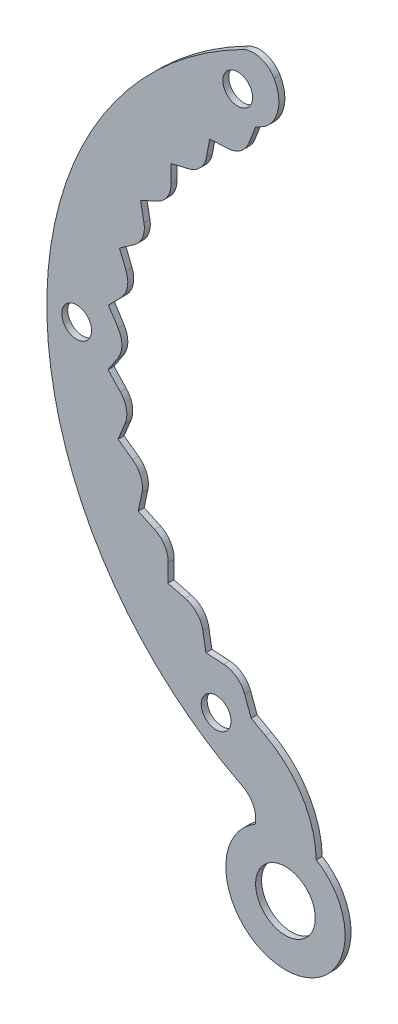
from build123d import *

# Parameters (mm, degrees)
IZIM1_R                     = 5
IZIM1_R_2                   = 2.5
Y_KSEKLIK_EKSTR_ZYON2_DEPTH = 1
SCALE1_SCALE                = 0.5


with BuildPart() as part:
    # Çizim1 → Yükseklik-Ekstrüzyon2 (new body)
    with BuildSketch(Plane.XY):
        with BuildLine():
            Line((-25, 43.301270189), (-26.146521576, 40.39207739))
            ThreePointArc((-26.146521576, 40.39207739), (-27.544598222, 38.602623821), (-29.691484877, 37.862596744))
            Line((-29.691484877, 37.862596744), (-32.693673826, 37.730024144))
            Line((-32.693673826, 37.730024144), (-33.252115355, 34.777253066))
            ThreePointArc((-33.252115355, 34.777253066), (-34.290118058, 32.757522199), (-36.260310201, 31.628316593))
            Line((-36.260310201, 31.628316593), (-39.184480502, 30.935538106))
            Line((-39.184480502, 30.935538106), (-39.17973637, 27.930427214))
            ThreePointArc((-39.17973637, 27.930427214), (-39.820893366, 25.751969023), (-41.54459596, 24.273587558))
            Line((-41.54459596, 24.273587558), (-44.287157421, 23.045145208))
            Line((-44.287157421, 23.045145208), (-43.719395692, 20.094152054))
            ThreePointArc((-43.719395692, 20.094152054), (-43.940993675, 17.834139505), (-45.357143694, 16.058954583))
            Line((-45.357143694, 16.058954583), (-47.82093971, 14.338366552))
            Line((-47.82093971, 14.338366552), (-46.710273625, 11.546031539))
            ThreePointArc((-46.710273625, 11.546031539), (-46.504462376, 9.284526705), (-47.562892001, 7.275425136))
            Line((-47.562892001, 7.275425136), (-49.660641368, 5.123644113))
            Line((-49.660641368, 5.123644113), (-48.046416828, 2.588887101))
            ThreePointArc((-48.046416828, 2.588887101), (-47.420487313, 0.406004917), (-48.083701146, -1.765839874))
            Line((-48.083701146, -1.765839874), (-49.741090048, -4.272585973))
            Line((-49.741090048, -4.272585973), (-47.680491761, -6.459969953))
            ThreePointArc((-47.680491761, -6.459969953), (-46.656617846, -8.486899797), (-46.901121207, -10.744549126))
            Line((-46.901121207, -10.744549126), (-48.059435816, -13.517457571))
            Line((-48.059435816, -13.517457571), (-45.625461503, -15.279979352))
            ThreePointArc((-45.625461503, -15.279979352), (-44.239914432, -17.079151855), (-44.057045667, -19.342627369))
            Line((-44.057045667, -19.342627369), (-44.675252109, -22.283466496))
            Line((-44.675252109, -22.283466496), (-41.954126526, -23.558687864))
            ThreePointArc((-41.954126526, -23.558687864), (-40.255989993, -25.066366444), (-39.652227319, -27.255483394))
            Line((-39.652227319, -27.255483394), (-39.708425324, -30.260072511))
            Line((-39.708425324, -30.260072511), (-36.7965457, -31.002818113))
            ThreePointArc((-36.7965457, -31.002818113), (-34.84597704, -32.165592505), (-33.842709051, -34.202800331))
            Line((-33.842709051, -34.202800331), (-33.334907776, -37.164700371))
            Line((-33.334907776, -37.164700371), (-30.335428898, -37.348658075))
            ThreePointArc((-30.335428898, -37.348658075), (-28.201527977, -38.125336415), (-26.834295942, -39.938466016))
            Line((-26.834295942, -39.938466016), (-25.73775467, -42.866863479))
            ThreePointArc((-25.73775467, -42.866863479), (-24.554196145, -43.55561332), (-23.352220135, -44.21169319))
            ThreePointArc((-23.352220135, -44.21169319), (-17.219408632, -49.939828574), (-14.829333353, -57.984109281))
            ThreePointArc((-14.829333353, -57.984109281), (-20.099106379, -76.543069457), (-25, -57.883306535))
            Line((-25, -57.883306535), (-25, -57.052607302))
            ThreePointArc((-25, -57.052607302), (-25.590454576, -54.960957236), (-27.1875, -53.486819346))
            ThreePointArc((-27.1875, -53.486819346), (-59.999999835, 0.004450967), (-27.179564099, 53.490852446))
            ThreePointArc((-27.179564099, 53.490852446), (-24.232021318, 53.76021953), (-21.906244367, 51.929556087))
            ThreePointArc((-21.906244367, 51.929556087), (-21.212806241, 47.755648425), (-23.446136356, 44.161959762))
            ThreePointArc((-23.446136356, 44.161959762), (-24.226890609, 43.73851588), (-25, 43.301270189))
        make_face()
        with Locations((-20, -66.543560573)):
            Circle(IZIM1_R, mode=Mode.SUBTRACT)
        with Locations((-31.620079453, -45.001895242)):
            Circle(IZIM1_R_2, mode=Mode.SUBTRACT)
        with Locations((-55, 0)):
            Circle(IZIM1_R_2, mode=Mode.SUBTRACT)
        with Locations((-28.000624989, 47.338831842)):
            Circle(IZIM1_R_2, mode=Mode.SUBTRACT)
    extrude(amount=Y_KSEKLIK_EKSTR_ZYON2_DEPTH)


with BuildPart() as part_1:
    # Scale1: scaled about (-39.321045235, -11.426802876, 0.5)
    add(part.part.scale(SCALE1_SCALE).moved(Location((-19.660522617, -5.713401438, 0.25))))


solid = part_1.part
